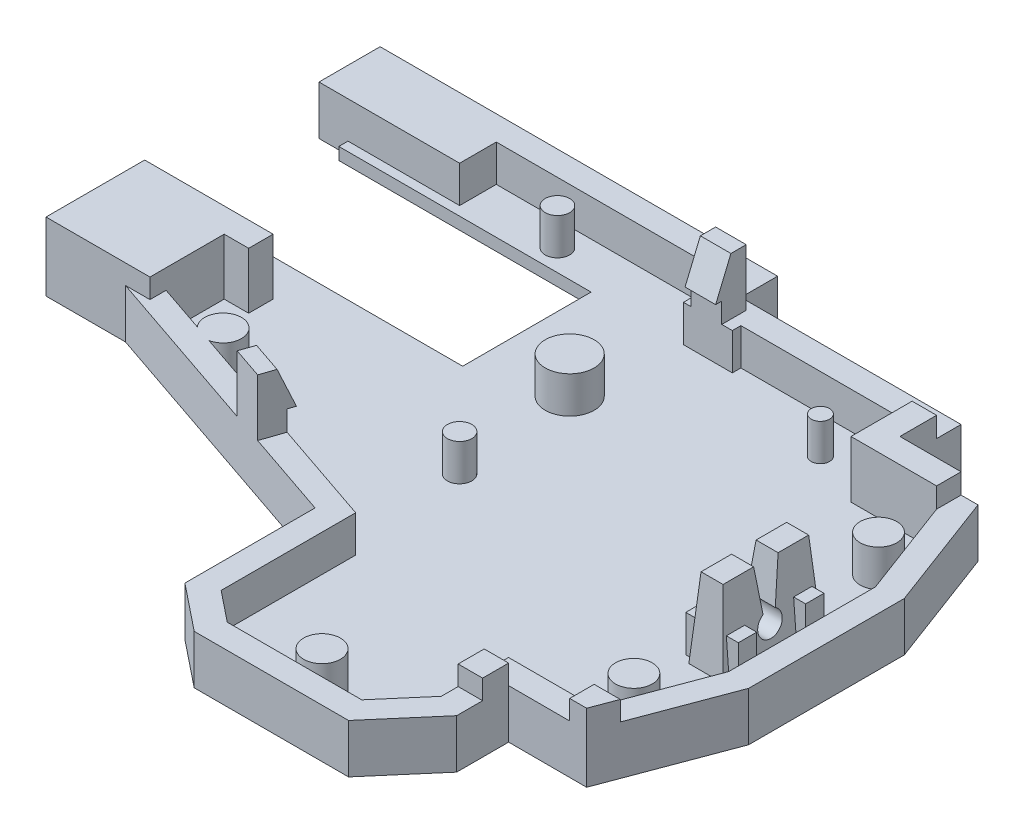
from build123d import *

# Parameters (mm, degrees)
SKETCH13_W           = 50
SKETCH13_H           = 45
BOSS_EXTRUDE4_DEPTH  = 1.6
SKETCH14_W           = 10
SKETCH14_H           = 8
CUT_EXTRUDE6_DEPTH   = 2.6
SKETCH15_W           = 18
SKETCH15_H           = 3
CUT_EXTRUDE7_DEPTH   = 2.6
SKETCH16_W           = 4
SKETCH16_H           = 0.7
CUT_EXTRUDE8_DEPTH   = 2.6
CUT_EXTRUDE9_DEPTH   = 2.6
SKETCH18_W           = 21.109590793
SKETCH18_H           = 22.840524871
CUT_EXTRUDE10_DEPTH  = 2.6
CUT_EXTRUDE11_DEPTH  = 2.6
SKETCH22_W           = 2
SKETCH22_H           = 3
CUT_EXTRUDE12_DEPTH  = 2.6
CUT_EXTRUDE13_DEPTH  = 2.6
CUT_EXTRUDE14_DEPTH  = 2.6
SKETCH25_W           = 2.8
SKETCH25_H           = 8
CUT_EXTRUDE15_DEPTH  = 2.6
BOSS_EXTRUDE6_DEPTH  = 6
SKETCH30_W           = 2.8
SKETCH30_H           = 8
BOSS_EXTRUDE7_DEPTH  = 3.5
CUT_EXTRUDE16_DEPTH  = 4.6
SKETCH32_W           = 2.8
SKETCH32_H           = 8
BOSS_EXTRUDE8_DEPTH  = 4.6
CUT_EXTRUDE18_DEPTH  = 4.6
SKETCH37_R           = 1
CUT_EXTRUDE19_DEPTH  = 4.6
CUT_EXTRUDE20_DEPTH  = 4.6
CUT_EXTRUDE21_START  = 6
CUT_EXTRUDE21_DEPTH  = 20.059798
BOSS_EXTRUDE9_DEPTH  = 4.6
SKETCH44_W           = 4.3
SKETCH44_H           = 1.5
BOSS_EXTRUDE11_DEPTH = 3
SKETCH45_R           = 1.5
SKETCH45_R_2         = 1
SKETCH45_R_3         = 1.999622229
SKETCH45_R_4         = 1.503341979
SKETCH45_R_5         = 0.75
BOSS_EXTRUDE12_DEPTH = 3
SKETCH46_W           = 2.5
SKETCH46_H           = 2
SKETCH46_W_2         = 2
BOSS_EXTRUDE13_DEPTH = 1.65
SKETCH47_W           = 3
SKETCH47_H           = 3
BOSS_EXTRUDE14_DEPTH = 3
SKETCH48_W           = 2
SKETCH48_H           = 16.336241737
CUT_EXTRUDE22_DEPTH  = 3
SKETCH49_W           = 21.336241737
SKETCH49_H           = 3
BOSS_EXTRUDE15_DEPTH = 13
SKETCH50_W           = 67
SKETCH50_H           = 49
BOSS_EXTRUDE16_DEPTH = 3
SKETCH51_W           = 5
SKETCH51_H           = 11
BOSS_EXTRUDE17_DEPTH = 15.6
CUT_EXTRUDE23_DEPTH  = 1.65
SKETCH53_W           = 2
SKETCH53_H           = 2.129349353
BOSS_EXTRUDE18_DEPTH = 1.6
SKETCH55_W           = 2.5
SKETCH55_H           = 2.5
BOSS_EXTRUDE20_DEPTH = 3
CUT_EXTRUDE24_DEPTH  = 3
SKETCH58_W           = 20
SKETCH58_H           = 10.5
SKETCH58_W_2         = 2
SKETCH58_H_2         = 2
CUT_EXTRUDE29_DEPTH  = 1
BOSS_EXTRUDE21_DEPTH = 3
BOSS_EXTRUDE22_REACH = 41.731
SKETCH61_W           = 2.5
SKETCH61_H           = 1.65
CUT_EXTRUDE30_DEPTH  = 3
CUT_EXTRUDE31_REACH  = 43.731
SKETCH64_W           = 2.551500858
SKETCH64_H           = 4.310788114
CUT_EXTRUDE32_DEPTH  = 4.65
SKETCH65_W           = 2
SKETCH65_H           = 2
BOSS_EXTRUDE23_DEPTH = 4
SKETCH66_W           = 2
SKETCH66_H           = 2
BOSS_EXTRUDE24_DEPTH = 1.6
SKETCH67_W           = 2.5
SKETCH67_H           = 2
BOSS_EXTRUDE25_DEPTH = 3
CUT_EXTRUDE33_DEPTH  = 3
BOSS_EXTRUDE26_DEPTH = 1.65
SKETCH70_W           = 5.055009343
SKETCH70_H           = 5.560438358
CUT_EXTRUDE34_DEPTH  = 3
BOSS_EXTRUDE27_DEPTH = 3
CUT_EXTRUDE35_DEPTH  = 3
BOSS_EXTRUDE28_REACH = 39.863
CUT_EXTRUDE36_DEPTH  = 3
FILLET8_R            = 1
SKETCH76_W           = 7
SKETCH76_H           = 14.5
BOSS_EXTRUDE29_DEPTH = 14.5
BOSS_EXTRUDE30_DEPTH = 2
CUT_EXTRUDE37_DEPTH  = 2
BOSS_EXTRUDE31_DEPTH = 2.684479
SKETCH85_W           = 30.566158209
SKETCH85_H           = 1.725230041
BOSS_EXTRUDE33_DEPTH = 3
BOSS_EXTRUDE34_DEPTH = 3
BOSS_EXTRUDE35_DEPTH = 3
SKETCH88_W           = 27.09375
SKETCH88_H           = 14.5
BOSS_EXTRUDE36_DEPTH = 1.6
SKETCH90_W           = 7
SKETCH90_H           = 14.5
BOSS_EXTRUDE37_DEPTH = 1.6
SKETCH93_W           = 5
SKETCH93_H           = 11
BOSS_EXTRUDE38_DEPTH = 0.5
SKETCH94_W           = 8.605758832
SKETCH94_H           = 2
BOSS_EXTRUDE39_DEPTH = 15.6
SKETCH96_W           = 8.605758832
SKETCH96_H           = 2
BOSS_EXTRUDE40_DEPTH = 0.5
SKETCH97_W           = 2
SKETCH97_H           = 49
BOSS_EXTRUDE41_DEPTH = 19.1
SKETCH98_W           = 69
SKETCH98_H           = 2
BOSS_EXTRUDE42_DEPTH = 19.1
SKETCH99_W           = 2
SKETCH99_H           = 3
BOSS_EXTRUDE43_DEPTH = 2.087376
SKETCH100_W          = 2
SKETCH100_H          = 51
BOSS_EXTRUDE45_DEPTH = 19.1
SKETCH101_W          = 71
SKETCH101_H          = 2
BOSS_EXTRUDE46_DEPTH = 19.1
BOSS_EXTRUDE47_DEPTH = 16.1
BOSS_EXTRUDE48_DEPTH = 16.1
FILLET9_R            = 2
SKETCH105_OUTSIDE_W  = 91.128
SKETCH105_OUTSIDE_H  = 73.128
CUT_EXTRUDE38_DEPTH  = 3
SKETCH106_W          = 77.0560479
SKETCH106_H          = 58.523580684
CUT_EXTRUDE39_DEPTH  = 20.1
SKETCH107_W          = 13.37564089
SKETCH107_H          = 6.179627402
CUT_EXTRUDE40_DEPTH  = 11.5
CUT_EXTRUDE41_DEPTH  = 4
SKETCH114_W          = 66.336817547
SKETCH114_H          = 51.668552302
CUT_EXTRUDE42_DEPTH  = 2
BOSS_EXTRUDE49_DEPTH = 6.5
SKETCH116_W          = 0.628599621
SKETCH116_H          = 10.5
CUT_EXTRUDE43_DEPTH  = 6.5
SKETCH117_W          = 8.5
SKETCH117_H          = 8.070282703
BOSS_EXTRUDE50_DEPTH = 1.6


with BuildPart() as part:
    # Sketch13 → Boss-Extrude4 (new body)
    with BuildSketch(Plane(origin=(0, 0, 0), x_dir=(1, 0, 0), z_dir=(0, 1, 0))):
        with Locations((25, -22.5)):
            Rectangle(SKETCH13_W, SKETCH13_H)
    extrude(amount=BOSS_EXTRUDE4_DEPTH)

    # Sketch14 → Cut-Extrude6 (cut, through all)
    with BuildSketch(Plane(origin=(0, 1.6, 0), x_dir=(1, 0, 0), z_dir=(0, 1, 0))):
        with Locations((45, -4)):
            Rectangle(SKETCH14_W, SKETCH14_H)
    extrude(amount=-CUT_EXTRUDE6_DEPTH, mode=Mode.SUBTRACT)

    # Sketch15 → Cut-Extrude7 (cut, through all)
    with BuildSketch(Plane(origin=(0, 1.6, 0), x_dir=(1, 0, 0), z_dir=(0, 1, 0))):
        with Locations((31, -1.5)):
            Rectangle(SKETCH15_W, SKETCH15_H)
    extrude(amount=-CUT_EXTRUDE7_DEPTH, mode=Mode.SUBTRACT)

    # Sketch16 → Cut-Extrude8 (cut, through all)
    with BuildSketch(Plane(origin=(0, 1.6, 0), x_dir=(1, 0, 0), z_dir=(0, 1, 0))):
        with Locations((24, -3.35)):
            Rectangle(SKETCH16_W, SKETCH16_H)
    extrude(amount=-CUT_EXTRUDE8_DEPTH, mode=Mode.SUBTRACT)

    # Sketch17 → Cut-Extrude9 (cut, through all)
    with BuildSketch(Plane(origin=(0, 1.6, 0), x_dir=(1, 0, 0), z_dir=(0, 1, 0))):
        Polygon((47, -8), (50, -16), (65.881056194, -16), (65.881056194, 17.957346821), (47, 17.957346821), align=None)
    extrude(amount=-CUT_EXTRUDE9_DEPTH, mode=Mode.SUBTRACT)

    # Sketch18 → Cut-Extrude10 (cut, through all)
    with BuildSketch(Plane(origin=(0, 1.6, 0), x_dir=(1, 0, 0), z_dir=(0, 1, 0))):
        with Locations((50.554795396, -47.420262436)):
            Rectangle(SKETCH18_W, SKETCH18_H)
    extrude(amount=-CUT_EXTRUDE10_DEPTH, mode=Mode.SUBTRACT)

    # Sketch21 → Cut-Extrude11 (cut, through all)
    with BuildSketch(Plane(origin=(0, 1.6, 0), x_dir=(1, 0, 0), z_dir=(0, 1, 0))):
        Polygon((50, -28), (47, -36), (47, -49.297594069), (75.196774358, -49.297594069), (75.196774358, -28), align=None)
    extrude(amount=-CUT_EXTRUDE11_DEPTH, mode=Mode.SUBTRACT)

    # Sketch22 → Cut-Extrude12 (cut, through all)
    with BuildSketch(Plane(origin=(0, 1.6, 0), x_dir=(1, 0, 0), z_dir=(0, 1, 0))):
        with Locations((1, -20.836241737)):
            Rectangle(SKETCH22_W, SKETCH22_H)
    extrude(amount=-CUT_EXTRUDE12_DEPTH, mode=Mode.SUBTRACT)

    # Sketch23 → Cut-Extrude13 (cut, through all)
    with BuildSketch(Plane(origin=(0, 1.6, 0), x_dir=(1, 0, 0), z_dir=(0, 1, 0))):
        Polygon((23.5, -45), (23.5, -32), (0, -26.336241737), (-30.2261683, -26.336241737), (-30.2261683, -63.188280898), (23.5, -63.188280898), align=None)
    extrude(amount=-CUT_EXTRUDE13_DEPTH, mode=Mode.SUBTRACT)

    # Sketch24 → Cut-Extrude14 (cut, through all)
    with BuildSketch(Plane(origin=(0, 1.6, 0), x_dir=(1, 0, 0), z_dir=(0, 1, 0))):
        Polygon((23.5, -43), (7.491129632, -43), (7.491129632, -69.550234766), (44.754002286, -69.550234766), (44.754002286, -41.5), (40, -41.5), (37, -45), (26, -45), align=None)
    extrude(amount=-CUT_EXTRUDE14_DEPTH, mode=Mode.SUBTRACT)

    # Sketch25 → Cut-Extrude15 (cut, through all)
    with BuildSketch(Plane(origin=(0, 1.6, 0), x_dir=(1, 0, 0), z_dir=(0, 1, 0))):
        with Locations((46.200745069, -22.059797812)):
            Rectangle(SKETCH25_W, SKETCH25_H)
    extrude(amount=-CUT_EXTRUDE15_DEPTH, mode=Mode.SUBTRACT)

    # Sketch28 → Boss-Extrude6 (add)
    with BuildSketch(Plane.XZ):
        Polygon((42, 38), (42, 42.239848152), (37.919869845, 47), (25.298437881, 47), (21.5, 43.961249695), (21.5, 33.575244456), (-2, 27.911486193), (-2, -2), (24, -2), (24, 1), (42, 1), (42, 6), (48.386000936, 6), (52, 15.637330836), (52, 28.362669164), (48.386000936, 38), align=None)
    extrude(amount=BOSS_EXTRUDE6_DEPTH)

    # Sketch30 → Boss-Extrude7 (add)
    with BuildSketch(Plane(origin=(0, 0, 0), x_dir=(1, 0, 0), z_dir=(0, 1, 0))):
        with Locations((46.200745069, -22.059797812)):
            Rectangle(SKETCH30_W, SKETCH30_H)
    extrude(amount=BOSS_EXTRUDE7_DEPTH)

    # Sketch31 → Cut-Extrude16 (cut)
    with BuildSketch(Plane(origin=(0, 1.6, 0), x_dir=(1, 0, 0), z_dir=(0, 1, 0))):
        Polygon((37, -45), (40, -41.5), (40, -36), (47, -36), (50, -28), (50, -16), (47, -8), (40, -8), (40, -3), (26, -3), (26, -3.7), (22, -3.7), (22, 0), (0, 0), (0, -19.336241737), (2, -19.336241737), (2, -22.336241737), (0, -22.336241737), (0, -26.336241737), (23.5, -32), (23.5, -43), (26, -45), align=None)
    extrude(amount=-CUT_EXTRUDE16_DEPTH, mode=Mode.SUBTRACT)

    # Sketch32 → Boss-Extrude8 (add)
    with BuildSketch(Plane.XZ.offset(-1.6)):
        with Locations((46.200745069, 22.059797812)):
            Rectangle(SKETCH32_W, SKETCH32_H)
    extrude(amount=BOSS_EXTRUDE8_DEPTH)

    # Sketch35 → Cut-Extrude18 (cut)
    with BuildSketch(Plane(origin=(47.600745069, 0, 0), x_dir=(0, 0, -1), z_dir=(1, 0, 0))):
        Polygon((-22.059797812, 0), (-21.559797812, 0), (-21.059797812, 3.5), (-21.297672794, 5.165124873), (-23.257672794, 4.885124873), (-23.059797812, 3.5), (-22.559797812, 0), align=None)
    extrude(amount=-CUT_EXTRUDE18_DEPTH, mode=Mode.SUBTRACT)

    # Sketch37 → Cut-Extrude19 (cut)
    with BuildSketch(Plane(origin=(47.600745069, 0, 0), x_dir=(0, 0, -1), z_dir=(1, 0, 0))):
        with Locations((-22.059797812, -0.866025404)):
            Circle(SKETCH37_R)
    extrude(amount=-CUT_EXTRUDE19_DEPTH, mode=Mode.SUBTRACT)

    # Sketch39 → Cut-Extrude20 (cut)
    with BuildSketch(Plane.ZY.offset(-44.800745069)):
        Polygon((25.559797812, 3.5), (26.059797812, -3), (27.906381513, -2.8579551), (27.406381513, 3.6420449), align=None)
        Polygon((18.559797812, 3.5), (18.059797812, -3), (15.957253652, -2.838265834), (16.455739093, 3.6420449), align=None)
    extrude(amount=-CUT_EXTRUDE20_DEPTH, mode=Mode.SUBTRACT)

    # Sketch41 → Cut-Extrude21 (cut)
    with BuildSketch(Plane.XY.offset(CUT_EXTRUDE21_START)):
        Polygon((45.300745069, 3.5), (44.800745069, -3), (43.414957387, -2.893400947), (43.940591177, 3.939838325), align=None)
        Polygon((47.100745069, 3.5), (47.600745069, -3), (49.658968536, -2.841675118), (49.137313656, 3.939838325), align=None)
    extrude(amount=CUT_EXTRUDE21_DEPTH, mode=Mode.SUBTRACT)

    # Sketch43 → Boss-Extrude9 (add)
    with BuildSketch(Plane(origin=(0, 0, 0), x_dir=(1, 0, 0), z_dir=(0, 1, 0))):
        Polygon((47, -8), (50, -16), (51.170411472, -13.425094762), (48.386000936, -6), (42.818763345, -6), (42.818763345, -8), align=None)
    extrude(amount=-BOSS_EXTRUDE9_DEPTH)

    # Sketch44 → Boss-Extrude11 (add)
    with BuildSketch(Plane(origin=(0, -3, 0), x_dir=(1, 0, 0), z_dir=(0, 1, 0))):
        with Locations((46.200745069, -19.309797812)):
            Rectangle(SKETCH44_W, SKETCH44_H)
        with Locations((46.200745069, -24.809797812)):
            Rectangle(SKETCH44_W, SKETCH44_H)
    extrude(amount=BOSS_EXTRUDE11_DEPTH)

    # Sketch45 → Boss-Extrude12 (add)
    with BuildSketch(Plane(origin=(0, -3, 0), x_dir=(1, 0, 0), z_dir=(0, 1, 0))):
        with Locations((46.25, -12)):
            Circle(SKETCH45_R)
        with Locations((46.25, -32)):
            Circle(SKETCH45_R)
        with Locations((22, -22)):
            Circle(SKETCH45_R_2)
        with Locations((21, -12)):
            Circle(SKETCH45_R_3)
        with Locations((31.75, -43)):
            Circle(SKETCH45_R_4)
        with Locations((35.5, -6)):
            Circle(SKETCH45_R_5)
        with Locations((10, -2)):
            Circle(SKETCH45_R_2)
        with Locations((5, -24.336241737)):
            Circle(SKETCH45_R)
    extrude(amount=BOSS_EXTRUDE12_DEPTH)

    # Sketch46 → Boss-Extrude13 (add)
    with BuildSketch(Plane(origin=(0, 0, 0), x_dir=(1, 0, 0), z_dir=(0, 1, 0))):
        Polygon((14.137316506, -29.743490383), (16.567726059, -30.329245795), (16.099121729, -32.273573438), (13.668712176, -31.687818026), align=None)
        with Locations((23.883625006, -2.7)):
            Rectangle(SKETCH46_W, SKETCH46_H)
        with Locations((1, -20.932723283)):
            Rectangle(SKETCH46_W_2, SKETCH46_H)
        Polygon((47, -36), (48.872658355, -36.702246883), (49.750466959, -34.361423939), (47.877808604, -33.659177056), align=None)
        Polygon((40, -3), (40, -8), (47, -8), (47, -6), (42, -6), (42, -3), align=None)
    extrude(amount=BOSS_EXTRUDE13_DEPTH)

    # Sketch47 → Boss-Extrude14 (add)
    with BuildSketch(Plane(origin=(0, 0, 0), x_dir=(1, 0, 0), z_dir=(0, 1, 0))):
        with Locations((1.5, -1.5)):
            Rectangle(SKETCH47_W, SKETCH47_H)
    extrude(amount=-BOSS_EXTRUDE14_DEPTH)

    # Sketch48 → Cut-Extrude22 (cut)
    with BuildSketch(Plane(origin=(0, 0, 0), x_dir=(1, 0, 0), z_dir=(0, 1, 0))):
        with Locations((-1, -11.168120869)):
            Rectangle(SKETCH48_W, SKETCH48_H)
    extrude(amount=-CUT_EXTRUDE22_DEPTH, mode=Mode.SUBTRACT)

    # Sketch49 → Boss-Extrude15 (add)
    with BuildSketch(Plane.ZY.offset(2)):
        with Locations((8.668120869, -4.5)):
            Rectangle(SKETCH49_W, SKETCH49_H)
    extrude(amount=BOSS_EXTRUDE15_DEPTH)

    # Sketch50 → Boss-Extrude16 (add)
    with BuildSketch(Plane.XZ.offset(6)):
        with Locations((18.5, 22.5)):
            Rectangle(SKETCH50_W, SKETCH50_H)
    extrude(amount=-BOSS_EXTRUDE16_DEPTH)

    # Sketch51 → Boss-Extrude17 (add)
    with BuildSketch(Plane(origin=(0, -3, 0), x_dir=(1, 0, 0), z_dir=(0, 1, 0))):
        with Locations((49.5, -41.5)):
            Rectangle(SKETCH51_W, SKETCH51_H)
    extrude(amount=BOSS_EXTRUDE17_DEPTH)

    # Sketch52 → Cut-Extrude23 (cut)
    with BuildSketch(Plane(origin=(0, 1.65, 0), x_dir=(1, 0, 0), z_dir=(0, 1, 0))):
        Polygon((47.877808604, -33.659177056), (47, -36), (49.136000936, -36), (49.750466959, -34.361423939), align=None)
    extrude(amount=-CUT_EXTRUDE23_DEPTH, mode=Mode.SUBTRACT)

    # Sketch53 → Boss-Extrude18 (add)
    with BuildSketch(Plane(origin=(0, 0, 0), x_dir=(1, 0, 0), z_dir=(0, 1, 0))):
        with Locations((41, -39.055249399)):
            Rectangle(SKETCH53_W, SKETCH53_H)
    extrude(amount=BOSS_EXTRUDE18_DEPTH)

    # Sketch55 → Boss-Extrude20 (add)
    with BuildSketch(Plane(origin=(0, 1.65, 0), x_dir=(1, 0, 0), z_dir=(0, 1, 0))):
        with Locations((23.883625006, -2.95)):
            Rectangle(SKETCH55_W, SKETCH55_H)
    extrude(amount=BOSS_EXTRUDE20_DEPTH)

    # Sketch56 → Cut-Extrude24 (cut)
    with BuildSketch(Plane(origin=(25.133625006, 0, 0), x_dir=(0, 0, -1), z_dir=(1, 0, 0))):
        Polygon((-4.2, 1.65), (-2.95, 4.65), (-2.95, 7.68728323), (-6.59715338, 7.68728323), (-6.59715338, 1.641289328), align=None)
    extrude(amount=-CUT_EXTRUDE24_DEPTH, mode=Mode.SUBTRACT)

    # Sketch58 → Cut-Extrude29 (cut)
    with BuildSketch(Plane(origin=(0, -3, 0), x_dir=(1, 0, 0), z_dir=(0, 1, 0))):
        with Locations((4.5, -9)):
            Rectangle(SKETCH58_W, SKETCH58_H)
        with Locations((1, -18.248866233)):
            Rectangle(SKETCH58_W_2, SKETCH58_H_2)
    extrude(amount=-CUT_EXTRUDE29_DEPTH, mode=Mode.SUBTRACT)

    # Sketch60 → Boss-Extrude21 (add)
    with BuildSketch(Plane(origin=(0, -3, 0), x_dir=(1, 0, 0), z_dir=(0, 1, 0))):
        Polygon((0, -24), (23.5, -32), (0, -26.336241737), align=None)
    extrude(amount=BOSS_EXTRUDE21_DEPTH)

    # Boss-Extrude22: up to this face of the body (flat: up to its plane)
    boss_extrude22_end = Plane(part.part.faces().sort_by_distance((14.401539714, -1.5, 28.902651818))[0])
    # Sketch61 → Boss-Extrude22 (add, up to the picked face)
    with BuildSketch(Plane(origin=(-5.998871461, 0, 24.890447788), x_dir=(-0.972163821, 0, -0.234302165), z_dir=(0.234302165, 0, -0.972163821)), mode=Mode.PRIVATE) as boss_extrude22_sk1:
        with Locations((-21.962751827, 0.825)):
            Rectangle(SKETCH61_W, SKETCH61_H)
    boss_extrude22_tool1 = split(extrude(boss_extrude22_sk1.sketch, amount=BOSS_EXTRUDE22_REACH, mode=Mode.PRIVATE), bisect_by=boss_extrude22_end, keep=Keep.BOTH, mode=Mode.PRIVATE)
    add(boss_extrude22_tool1.solids().sort_by_distance((15.352521, 0.825, 30.036368))[0])

    # Sketch62 → Cut-Extrude30 (cut)
    with BuildSketch(Plane(origin=(0, 0, 0), x_dir=(1, 0, 0), z_dir=(0, 1, 0))):
        Polygon((0, -26), (-0.545193502, -28.262110548), (-9.931116312, -26), (-9.25988925, -22.847697277), align=None)
    extrude(amount=-CUT_EXTRUDE30_DEPTH, mode=Mode.SUBTRACT)

    # Cut-Extrude31: up to this face of the body (flat: up to its plane)
    cut_extrude31_end = Plane(part.part.faces().sort_by_distance((-1, -1.5, 25.659574468))[0])
    # Sketch63 → Cut-Extrude31 (cut, up to the picked face)
    with BuildSketch(Plane(origin=(-6.46747579, 0, 26.834775431), x_dir=(0.972163821, 0, 0.234302165), z_dir=(-0.234302165, 0, 0.972163821)), mode=Mode.PRIVATE) as cut_extrude31_sk1:
        Polygon((20.712751827, 0), (6.091856288, 0), (6.091856288, -3), (28.768274623, -3), (28.768274623, 0), (23.212751827, 0), (23.212751827, 1.65), (20.712751827, 1.65), align=None)
    cut_extrude31_tool1 = split(extrude(cut_extrude31_sk1.sketch, amount=-CUT_EXTRUDE31_REACH, mode=Mode.PRIVATE), bisect_by=cut_extrude31_end, keep=Keep.BOTH, mode=Mode.PRIVATE)
    add(cut_extrude31_tool1.solids().sort_by_distance((10.72932, -1.367082, 30.979392))[0], mode=Mode.SUBTRACT)

    # Sketch64 → Cut-Extrude32 (cut)
    with BuildSketch(Plane(origin=(0, 1.65, 0), x_dir=(1, 0, 0), z_dir=(0, 1, 0))):
        with Locations((1.275750429, -20.806985271)):
            Rectangle(SKETCH64_W, SKETCH64_H)
    extrude(amount=-CUT_EXTRUDE32_DEPTH, mode=Mode.SUBTRACT)

    # Sketch65 → Boss-Extrude23 (add)
    with BuildSketch(Plane(origin=(0, -4, 0), x_dir=(1, 0, 0), z_dir=(0, 1, 0))):
        with Locations((1, -18.248866233)):
            Rectangle(SKETCH65_W, SKETCH65_H)
    extrude(amount=BOSS_EXTRUDE23_DEPTH)

    # Sketch66 → Boss-Extrude24 (add)
    with BuildSketch(Plane(origin=(0, 0, 0), x_dir=(1, 0, 0), z_dir=(0, 1, 0))):
        with Locations((1, -18.248866233)):
            Rectangle(SKETCH66_W, SKETCH66_H)
    extrude(amount=BOSS_EXTRUDE24_DEPTH)

    # Sketch67 → Boss-Extrude25 (add)
    with BuildSketch(Plane(origin=(0, 1.6, 0), x_dir=(1, 0, 0), z_dir=(0, 1, 0))):
        with Locations((1.25, -18.248866233)):
            Rectangle(SKETCH67_W, SKETCH67_H)
    extrude(amount=BOSS_EXTRUDE25_DEPTH)

    # Sketch68 → Cut-Extrude33 (cut)
    with BuildSketch(Plane(origin=(0, 0, 17.248866233), x_dir=(-1, 0, 0), z_dir=(0, 0, -1))):
        Polygon((-2.5, 1.6), (-1.25, 4.6), (-1.25, 6.77486743), (-4.497451498, 6.77486743), (-4.497451498, 1.567063174), align=None)
    extrude(amount=-CUT_EXTRUDE33_DEPTH, mode=Mode.SUBTRACT)

    # Sketch69 → Boss-Extrude26 (add)
    with BuildSketch(Plane(origin=(0, 1.65, 0), x_dir=(1, 0, 0), z_dir=(0, 1, 0))):
        Polygon((14.344636536, -28.883280523), (16.885898362, -29.748390932), (16.275756374, -31.540683021), (13.734494548, -30.675572612), align=None)
    extrude(amount=-BOSS_EXTRUDE26_DEPTH)

    # Sketch70 → Cut-Extrude34 (cut)
    with BuildSketch(Plane.XY.offset(19.248866233)):
        with Locations((-0.027504672, 4.380219179)):
            Rectangle(SKETCH70_W, SKETCH70_H)
    extrude(amount=-CUT_EXTRUDE34_DEPTH, mode=Mode.SUBTRACT)

    # Sketch71 → Boss-Extrude27 (add)
    with BuildSketch(Plane(origin=(0, 1.65, 0), x_dir=(1, 0, 0), z_dir=(0, 1, 0))):
        Polygon((16.275756374, -31.540683021), (17.081415869, -29.174058256), (14.559846057, -28.298525857), (13.734494548, -30.675572612), align=None)
    extrude(amount=BOSS_EXTRUDE27_DEPTH)

    # Sketch72 → Cut-Extrude35 (cut)
    with BuildSketch(Plane(origin=(24.207602216, 0, 8.240885861), x_dir=(0.322263798, 0, -0.946649906), z_dir=(0.946649906, 0, 0.322263798))):
        Polygon((-22.112897557, 1.65), (-23.362897557, 4.65), (-23.362897557, 7.694800469), (-20.734818485, 7.694800469), (-20.734818485, 1.65), align=None)
    extrude(amount=-CUT_EXTRUDE35_DEPTH, mode=Mode.SUBTRACT)

    # Boss-Extrude28: up to this face of the body (flat: up to its plane)
    boss_extrude28_end = Plane(part.part.faces().sort_by_distance((14.039565542, 0.825, 29.779426567))[0])
    # Sketch73 → Boss-Extrude28 (add, up to the picked face)
    with BuildSketch(Plane(origin=(21.761963317, 0, 7.556127878), x_dir=(-0.328007452, 0, 0.944675136), z_dir=(-0.944675136, 0, -0.328007452)), mode=Mode.PRIVATE) as boss_extrude28_sk1:
        Polygon((24.473434161, 4.65), (23.223411105, 4.65), (21.973388049, 1.65), (22.580099427, 1.65), (24.473434161, 1.65), align=None)
    boss_extrude28_tool1 = split(extrude(boss_extrude28_sk1.sketch, amount=BOSS_EXTRUDE28_REACH, mode=Mode.PRIVATE), bisect_by=boss_extrude28_end, keep=Keep.BOTH, mode=Mode.PRIVATE)
    add(boss_extrude28_tool1.solids().sort_by_distance((14.053397, 2.983333, 29.757122))[0])

    # Sketch74 → Cut-Extrude36 (cut)
    with BuildSketch(Plane(origin=(0, -4, 0), x_dir=(1, 0, 0), z_dir=(0, 1, 0))):
        with BuildLine():
            Line((6.419171569, -6.169171569), (2.580828431, -6.169171569))
            ThreePointArc((2.580828431, -6.169171569), (-0.25, -9), (2.580828431, -11.830828431))
            Line((2.580828431, -11.830828431), (6.419171569, -11.830828431))
            ThreePointArc((6.419171569, -11.830828431), (9.25, -9), (6.419171569, -6.169171569))
        make_face()
    extrude(amount=-CUT_EXTRUDE36_DEPTH, mode=Mode.SUBTRACT)

    # Fillet8
    fillet8_edges = [part.edges().sort_by_distance(p)[0] for p in [
        (-0.25, -6, 9),
        (4.5, -6, 6.169171569),
        (9.25, -6, 9),
        (4.5, -6, 11.830828431),
    ]]
    fillet(fillet8_edges, radius=FILLET8_R)

    # Sketch76 → Boss-Extrude29 (add)
    with BuildSketch(Plane(origin=(0, -3, 0), x_dir=(1, 0, 0), z_dir=(0, 1, 0))):
        with Locations((-11.5, -39.75)):
            Rectangle(SKETCH76_W, SKETCH76_H)
    extrude(amount=BOSS_EXTRUDE29_DEPTH)

    # Sketch79 → Boss-Extrude30 (add)
    with BuildSketch(Plane(origin=(21.66634039, 0, 7.375775452), x_dir=(-0.322263798, 0, 0.946649906), z_dir=(-0.946649906, 0, -0.322263798))):
        Polygon((22.719597745, 0), (24.612897557, 0), (24.612897557, 4.65), (23.362851444, 4.65), (22.112805332, 1.65), (22.719597745, 1.65), align=None)
    extrude(amount=BOSS_EXTRUDE30_DEPTH)

    # Sketch80 → Cut-Extrude37 (cut)
    with BuildSketch(Plane(origin=(24.207602216, 0, 8.240885861), x_dir=(0.322263798, 0, -0.946649906), z_dir=(0.946649906, 0, 0.322263798))):
        Polygon((-22.112897557, 1.65), (-23.362897557, 4.65), (-24.612897557, 4.65), (-24.612897557, 0), (-22.719597745, 0), (-22.719597745, 1.65), align=None)
    extrude(amount=-CUT_EXTRUDE37_DEPTH, mode=Mode.SUBTRACT)

    # Sketch83 → Boss-Extrude31 (add)
    with BuildSketch(Plane(origin=(19.773040578, 0, 6.731247856), x_dir=(-0.322263798, 0, 0.946649906), z_dir=(-0.946649906, 0, -0.322263798))):
        Polygon((22.719597745, 1.65), (22.719597745, 0), (24.612897557, 0), (24.612897557, 4.65), (23.362851444, 4.65), (22.112805332, 1.65), align=None)
    extrude(amount=-BOSS_EXTRUDE31_DEPTH)

    # Sketch85 → Boss-Extrude33 (add)
    with BuildSketch(Plane(origin=(0, -3, 0), x_dir=(1, 0, 0), z_dir=(0, 1, 0))):
        with Locations((7.283079105, -33.362615021)):
            Rectangle(SKETCH85_W, SKETCH85_H)
    extrude(amount=BOSS_EXTRUDE33_DEPTH)

    # Sketch86 → Boss-Extrude34 (add)
    with BuildSketch(Plane(origin=(0, -3, 0), x_dir=(1, 0, 0), z_dir=(0, 1, 0))):
        Polygon((21.5, -43.961249695), (21.5, -34.225230041), (-8, -34.225230041), (-8, -47), (25.298437881, -47), align=None)
    extrude(amount=BOSS_EXTRUDE34_DEPTH)

    # Sketch87 → Boss-Extrude35 (add)
    with BuildSketch(Plane(origin=(0, -3, 0), x_dir=(1, 0, 0), z_dir=(0, 1, 0))):
        Polygon((37.919869845, -47), (47, -47), (47, -38), (42, -38), (42, -42.239848152), align=None)
    extrude(amount=BOSS_EXTRUDE35_DEPTH)

    # Sketch88 → Boss-Extrude36 (add)
    with BuildSketch(Plane(origin=(0, 0, 0), x_dir=(1, 0, 0), z_dir=(0, 1, 0))):
        with Locations((5.546875, -39.75)):
            Rectangle(SKETCH88_W, SKETCH88_H)
    extrude(amount=BOSS_EXTRUDE36_DEPTH)

    # Sketch90 → Boss-Extrude37 (add)
    with BuildSketch(Plane(origin=(0, 11.5, 0), x_dir=(1, 0, 0), z_dir=(0, 1, 0))):
        with Locations((-11.5, -39.75)):
            Rectangle(SKETCH90_W, SKETCH90_H)
    extrude(amount=BOSS_EXTRUDE37_DEPTH)

    # Sketch93 → Boss-Extrude38 (add)
    with BuildSketch(Plane(origin=(0, 12.6, 0), x_dir=(1, 0, 0), z_dir=(0, 1, 0))):
        with Locations((49.5, -41.5)):
            Rectangle(SKETCH93_W, SKETCH93_H)
    extrude(amount=BOSS_EXTRUDE38_DEPTH)

    # Sketch94 → Boss-Extrude39 (add)
    with BuildSketch(Plane(origin=(0, -3, 0), x_dir=(1, 0, 0), z_dir=(0, 1, 0))):
        with Locations((5.421445221, -31.5)):
            Rectangle(SKETCH94_W, SKETCH94_H)
    extrude(amount=BOSS_EXTRUDE39_DEPTH)

    # Sketch96 → Boss-Extrude40 (add)
    with BuildSketch(Plane(origin=(0, 12.6, 0), x_dir=(1, 0, 0), z_dir=(0, 1, 0))):
        with Locations((5.421445221, -31.5)):
            Rectangle(SKETCH96_W, SKETCH96_H)
    extrude(amount=BOSS_EXTRUDE40_DEPTH)

    # Sketch97 → Boss-Extrude41 (add)
    with BuildSketch(Plane.XZ.offset(6)):
        with Locations((-16, 22.5)):
            Rectangle(SKETCH97_W, SKETCH97_H)
    extrude(amount=-BOSS_EXTRUDE41_DEPTH)

    # Sketch98 → Boss-Extrude42 (add)
    with BuildSketch(Plane.XZ.offset(6)):
        with Locations((17.5, 48)):
            Rectangle(SKETCH98_W, SKETCH98_H)
    extrude(amount=-BOSS_EXTRUDE42_DEPTH)

    # Sketch99 → Boss-Extrude43 (add)
    with BuildSketch(Plane(origin=(0, 0, 19.336241737), x_dir=(-1, 0, 0), z_dir=(0, 0, -1))):
        with Locations((1, -1.5)):
            Rectangle(SKETCH99_W, SKETCH99_H)
    extrude(amount=BOSS_EXTRUDE43_DEPTH)

    # Sketch100 → Boss-Extrude45 (add)
    with BuildSketch(Plane.XZ.offset(6)):
        with Locations((53, 23.5)):
            Rectangle(SKETCH100_W, SKETCH100_H)
    extrude(amount=-BOSS_EXTRUDE45_DEPTH)

    # Sketch101 → Boss-Extrude46 (add)
    with BuildSketch(Plane.XZ.offset(6)):
        with Locations((18.5, -3)):
            Rectangle(SKETCH101_W, SKETCH101_H)
    extrude(amount=-BOSS_EXTRUDE46_DEPTH)

    # Sketch102 → Boss-Extrude47 (add)
    with BuildSketch(Plane(origin=(0, -3, 0), x_dir=(1, 0, 0), z_dir=(0, 1, 0))):
        with BuildLine():
            Line((50, 2), (50, 2.836676417))
            Line((50, 2.836676417), (52.928518438, 2.836676417))
            Line((52.928518438, 2.836676417), (52.928518438, 0))
            Line((52.928518438, 0), (52, 0))
            ThreePointArc((52, 0), (51.414213562, 1.414213562), (50, 2))
        make_face()
    extrude(amount=BOSS_EXTRUDE47_DEPTH)

    # Sketch103 → Boss-Extrude48 (add)
    with BuildSketch(Plane(origin=(0, -3, 0), x_dir=(1, 0, 0), z_dir=(0, 1, 0))):
        with BuildLine():
            Line((-13, 2), (-13, 3.319267165))
            Line((-13, 3.319267165), (-16.315139414, 3.319267165))
            Line((-16.315139414, 3.319267165), (-16.315139414, 0))
            Line((-16.315139414, 0), (-15, 0))
            ThreePointArc((-15, 0), (-14.414213562, 1.414213562), (-13, 2))
        make_face()
    extrude(amount=BOSS_EXTRUDE48_DEPTH)

    # Fillet9
    fillet9_edges = [part.edges().sort_by_distance(p)[0] for p in [
        (-17, -6, 22.5),
        (18.5, -6, 49),
        (-17, 3.55, 49),
        (54, -6, 22.5),
        (54, 3.55, 49),
        (18.5, -6, -4),
        (-17, 3.55, -4),
        (54, 3.55, -4),
    ]]
    fillet(fillet9_edges, radius=FILLET9_R)

    # Sketch105 outside → Cut-Extrude38 (cut)
    with BuildSketch(Plane(origin=(0, 13.1, 0), x_dir=(1, 0, 0), z_dir=(0, 1, 0))):
        with Locations((18.5, -22.5)):
            Rectangle(SKETCH105_OUTSIDE_W, SKETCH105_OUTSIDE_H)
        with BuildLine():
            Line((-16, 2), (-16, -47))
            ThreePointArc((-16, -47), (-15.707106781, -47.707106781), (-15, -48))
            Line((-15, -48), (52, -48))
            ThreePointArc((52, -48), (52.707106781, -47.707106781), (53, -47))
            Line((53, -47), (53, 2))
            ThreePointArc((53, 2), (52.707106781, 2.707106781), (52, 3))
            Line((52, 3), (-15, 3))
            ThreePointArc((-15, 3), (-15.707106781, 2.707106781), (-16, 2))
        make_face(mode=Mode.SUBTRACT)
    extrude(amount=-CUT_EXTRUDE38_DEPTH, mode=Mode.SUBTRACT)

    # Sketch106 → Cut-Extrude39 (cut, through all)
    with BuildSketch(Plane.XZ.offset(6)):
        with Locations((17.692589571, 21.631481201)):
            Rectangle(SKETCH106_W, SKETCH106_H)
        Polygon((-2, -2), (24, -2), (24, 1), (42, 1), (42, 6), (48.386000936, 6), (52, 15.637330836), (52, 28.362669164), (49.136000936, 36), (48.386000936, 38), (42, 37.990574723), (42, 42.239848152), (37.919869845, 47), (25.298437881, 47), (21.5, 43.961249695), (21.5, 33.319148936), (-2, 25.319148936), (-2, 17.248866233), (-8.372079234, 17.248866233), (-8.372079234, 3), (-2, 3), align=None, mode=Mode.SUBTRACT)
    extrude(amount=-CUT_EXTRUDE39_DEPTH, mode=Mode.SUBTRACT)

    # Sketch107 → Cut-Extrude40 (cut)
    with BuildSketch(Plane(origin=(0, 13.1, 0), x_dir=(1, 0, 0), z_dir=(0, 1, 0))):
        with Locations((44.784273424, -38.274312053)):
            Rectangle(SKETCH107_W, SKETCH107_H)
    extrude(amount=-CUT_EXTRUDE40_DEPTH, mode=Mode.SUBTRACT)

    # Sketch113 → Cut-Extrude41 (cut, through all)
    with BuildSketch(Plane(origin=(0, -3, 0), x_dir=(1, 0, 0), z_dir=(0, 1, 0))):
        Polygon((-6.128599621, -3), (-6.128599621, -14.861393841), (-2, -14.861393841), (-2, -17.248866233), (-9.246534053, -26.452427809), (-13.814435406, -0.657200841), (-2.974123127, 6.68981616), (-3.537653946, 5.974095989), align=None)
    extrude(amount=-CUT_EXTRUDE41_DEPTH, mode=Mode.SUBTRACT)

    # Sketch114 → Cut-Extrude42 (cut)
    with BuildSketch(Plane.XZ.offset(6)):
        with Locations((24.645555619, 22.809022442)):
            Rectangle(SKETCH114_W, SKETCH114_H)
    extrude(amount=-CUT_EXTRUDE42_DEPTH, mode=Mode.SUBTRACT)

    # Sketch115 → Boss-Extrude49 (add)
    with BuildSketch(Plane.ZY.offset(2)):
        Polygon((14.861393841, -3), (14.861393841, -4), (25.319148936, -4), (25.319148936, 0), (17.248866233, 0), (17.248866233, -3), align=None)
        Polygon((-2, 0), (-2, -4), (3, -4), (3, -3), (3, 0), align=None)
    extrude(amount=BOSS_EXTRUDE49_DEPTH)

    # Sketch116 → Cut-Extrude43 (cut)
    with BuildSketch(Plane(origin=(0, -3, 0), x_dir=(1, 0, 0), z_dir=(0, 1, 0))):
        with Locations((-5.81429981, -9)):
            Rectangle(SKETCH116_W, SKETCH116_H)
    extrude(amount=-CUT_EXTRUDE43_DEPTH, mode=Mode.SUBTRACT)

    # Sketch117 → Boss-Extrude50 (add)
    with BuildSketch(Plane(origin=(0, 0, 0), x_dir=(1, 0, 0), z_dir=(0, 1, 0))):
        with Locations((-4.25, -21.284007585)):
            Rectangle(SKETCH117_W, SKETCH117_H)
    extrude(amount=BOSS_EXTRUDE50_DEPTH)


solid = part.part
